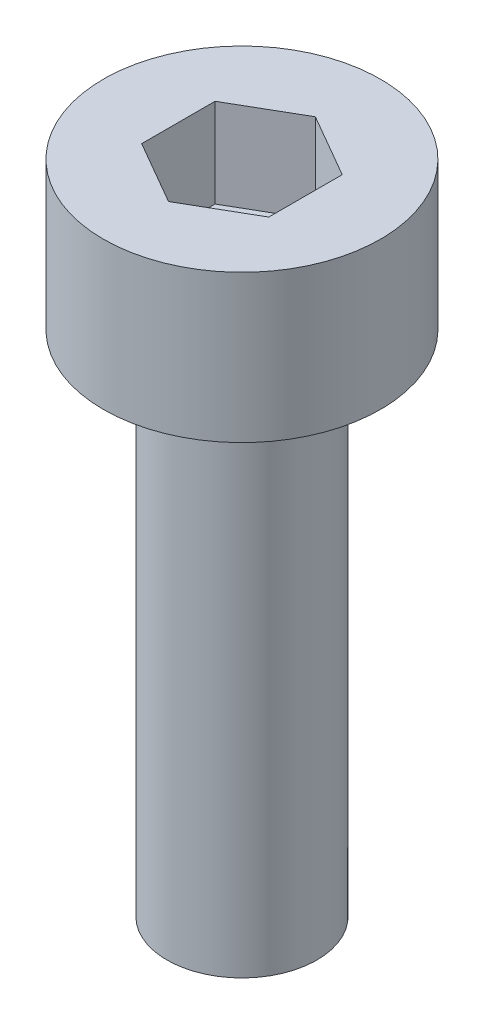
from build123d import *

# Parameters (mm, degrees)
SKETCH1_R           = 2.725
BOSS_EXTRUDE1_DEPTH = 2.9
SKETCH2_R           = 1.475
BOSS_EXTRUDE2_DEPTH = 10
CUT_EXTRUDE1_DEPTH  = 1.75


with BuildPart() as part:
    # Sketch1 → Boss-Extrude1 (new body)
    with BuildSketch(Plane(origin=(0, 0, 0), x_dir=(1, 0, 0), z_dir=(0, 1, 0))):
        Circle(SKETCH1_R)
    extrude(amount=BOSS_EXTRUDE1_DEPTH)

    # Sketch2 → Boss-Extrude2 (add)
    with BuildSketch(Plane.XZ):
        Circle(SKETCH2_R)
    extrude(amount=BOSS_EXTRUDE2_DEPTH)

    # Sketch3 → Cut-Extrude1 (cut)
    with BuildSketch(Plane(origin=(0, 2.9, 0), x_dir=(1, 0, 0), z_dir=(0, 1, 0))):
        Polygon((0, 1.443375673), (-1.25, 0.721687836), (-1.25, -0.721687836), (0, -1.443375673), (1.25, -0.721687836), (1.25, 0.721687836), align=None)
    extrude(amount=-CUT_EXTRUDE1_DEPTH, mode=Mode.SUBTRACT)


solid = part.part
